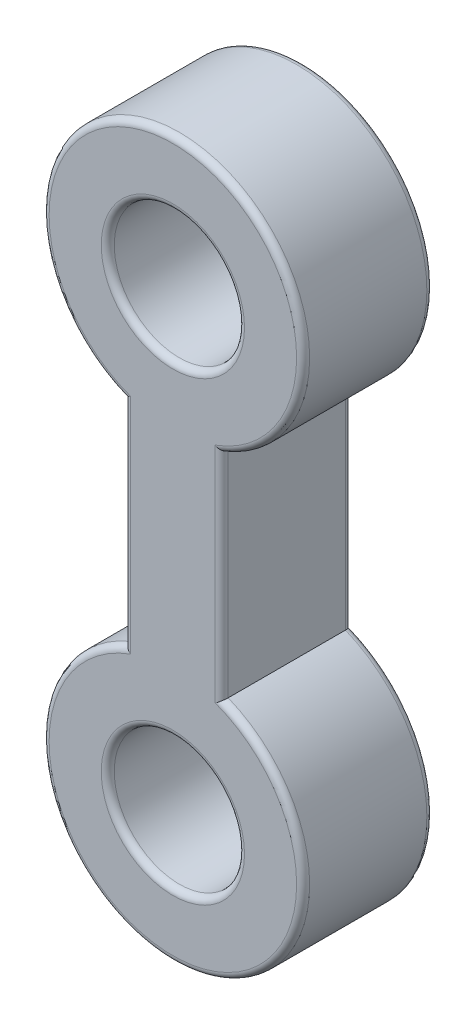
from build123d import *

# Parameters (mm, degrees)
SKETCH1_R           = 10
BOSS_EXTRUDE1_DEPTH = 10
FILLET1_R           = 1


with BuildPart() as part:
    # Sketch1 → Boss-Extrude1 (new body, symmetric)
    with BuildSketch(Plane.XY):
        with BuildLine():
            Line((7.5, -18.540496218), (7.5, -51.459503782))
            ThreePointArc((7.5, -51.459503782), (0, -90), (-7.5, -51.459503782))
            Line((-7.5, -51.459503782), (-7.5, -18.540496218))
            ThreePointArc((-7.5, -18.540496218), (0, 20), (7.5, -18.540496218))
        make_face()
        Circle(SKETCH1_R, mode=Mode.SUBTRACT)
        with Locations((0, -70)):
            Circle(SKETCH1_R, mode=Mode.SUBTRACT)
    extrude(amount=BOSS_EXTRUDE1_DEPTH, both=True)

    # Fillet1
    fillet1_edges = [part.edges().sort_by_distance(p)[0] for p in [
        (-10, 0, -10),
        (-10, 0, 10),
        (0, -90, 10),
        (-10, -70, -10),
        (-10, -70, 10),
        (7.5, -35, 10),
        (0, 20, 10),
        (7.5, -35, -10),
        (0, -90, -10),
        (-7.5, -35, -10),
        (0, 20, -10),
        (-7.5, -35, 10),
    ]]
    fillet(fillet1_edges, radius=FILLET1_R)


solid = part.part
